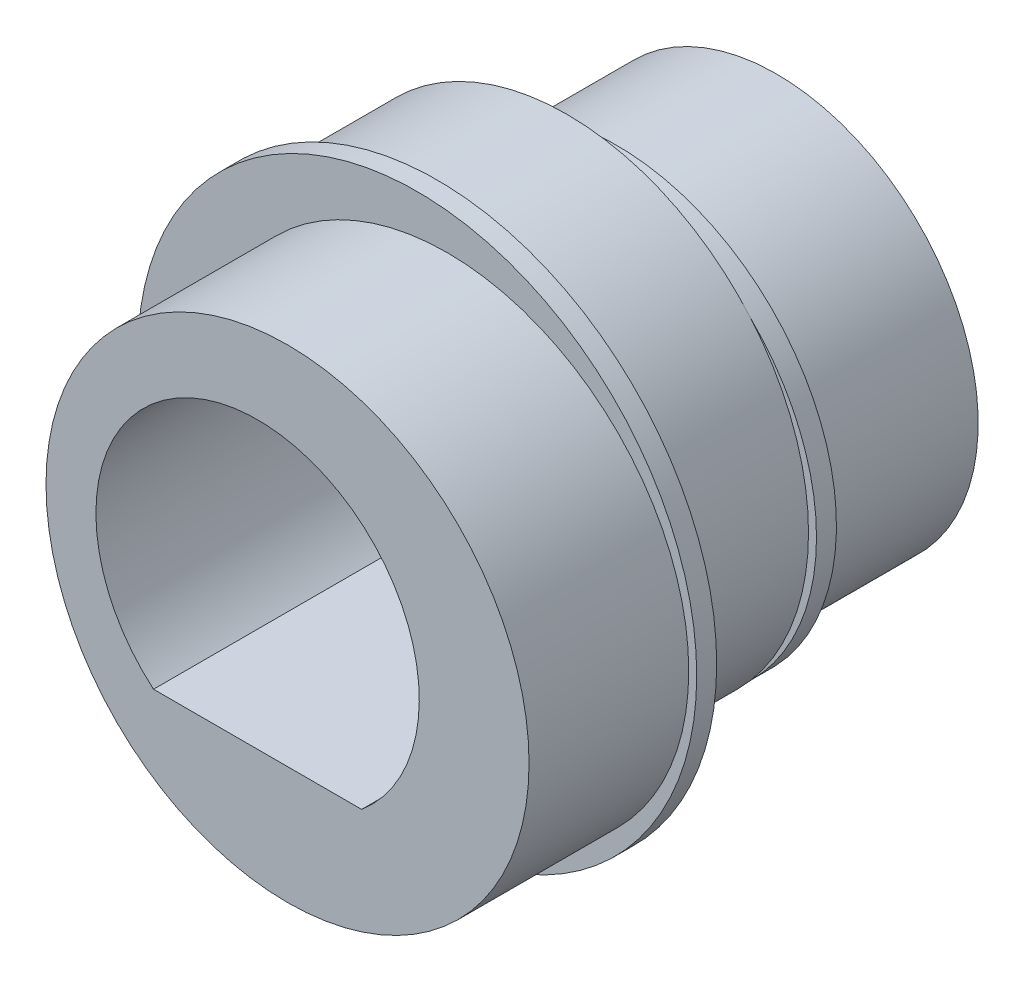
from build123d import *

# Parameters (mm, degrees)
SKETCH_1_R          = 6.05
EXTRUDE_1_DEPTH     = 4
SKETCH_2_R          = 7
EXTRUDE_2_DEPTH     = 0.5
SKETCH_3_R          = 6.05
EXTRUDE_3_DEPTH     = 4
SKETCH_5_R          = 5.5
EXTRUDE_4_DEPTH     = 0.5
SKETCH_6_R          = 5.05
EXTRUDE_5_DEPTH     = 4
CUT_EXTRUDE_1_DEPTH = 14


with BuildPart() as part:
    # 草图1 → 凸台-拉伸1 (new body)
    with BuildSketch(Plane.XY):
        with Locations((-0.75, 0)):
            Circle(SKETCH_1_R)
    extrude(amount=EXTRUDE_1_DEPTH)

    # 草图2 → 凸台-拉伸2 (add)
    with BuildSketch(Plane.XY.offset(4)):
        Circle(SKETCH_2_R)
    extrude(amount=EXTRUDE_2_DEPTH)

    # 草图3 → 凸台-拉伸3 (add)
    with BuildSketch(Plane.XY.offset(4.5)):
        with Locations((0.75, 0)):
            Circle(SKETCH_3_R)
    extrude(amount=EXTRUDE_3_DEPTH)

    # 草图5 → 凸台-拉伸4 (add)
    with BuildSketch(Plane(origin=(0, 0, 0), x_dir=(-1, 0, 0), z_dir=(0, 0, -1))):
        Circle(SKETCH_5_R)
    extrude(amount=EXTRUDE_4_DEPTH)

    # 草图6 → 凸台-拉伸5 (add)
    with BuildSketch(Plane(origin=(0, 0, -0.5), x_dir=(-1, 0, 0), z_dir=(0, 0, -1))):
        Circle(SKETCH_6_R)
    extrude(amount=EXTRUDE_5_DEPTH)

    # 草图4 → 切除-拉伸1 (cut, through all)
    with BuildSketch(Plane.XY.offset(8.5)):
        with BuildLine():
            ThreePointArc((4.05, 0), (-1.709856405, 3.671360929), (-2.606242506, -3.1))
            Line((-2.606242506, -3.1), (2.606242506, -3.1))
            ThreePointArc((2.606242506, -3.1), (3.671360929, -1.709856405), (4.05, 0))
        make_face()
    extrude(amount=-CUT_EXTRUDE_1_DEPTH, mode=Mode.SUBTRACT)


solid = part.part
